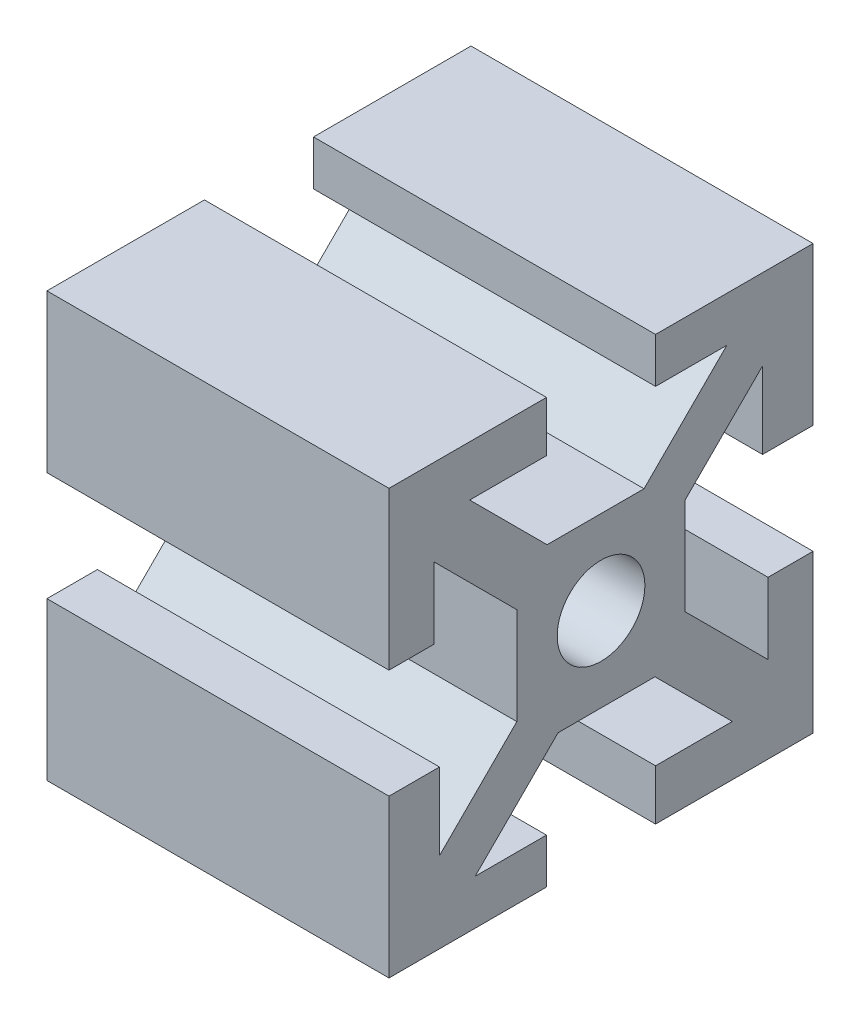
from build123d import *

# Parameters (mm, degrees)
SKETCH1_R           = 2.605
BOSS_EXTRUDE1_DEPTH = 20.32
CIRPATTERN1_COUNT   = 4


with BuildPart() as part:
    # Sketch1 → Boss-Extrude1 (new body)
    with BuildSketch(Plane(origin=(0, 0, 0), x_dir=(0, 0, -1), z_dir=(1, 0, 0))):
        Polygon((5, -5), (5, 3.203948776), (9.596194078, 7.800142853), (9.596194078, 3.24), (12.596194078, 3.24), (12.596194078, 12.596194078), (3.24, 12.596194078), (3.24, 9.921463197), (7.474873734, 9.921463197), (2.553410537, 5), (-5, 5), (-5, -5), align=None)
        Circle(SKETCH1_R, mode=Mode.SUBTRACT)
    boss_extrude1 = extrude(amount=BOSS_EXTRUDE1_DEPTH)

    # CirPattern1: Boss-Extrude1 ×4 about axis
    cirpattern1_axis = Axis((0, 0, 0), (1, 0, 0))
    for i in range(1, CIRPATTERN1_COUNT):
        add(boss_extrude1.rotate(cirpattern1_axis, i * 360 / CIRPATTERN1_COUNT))


solid = part.part
